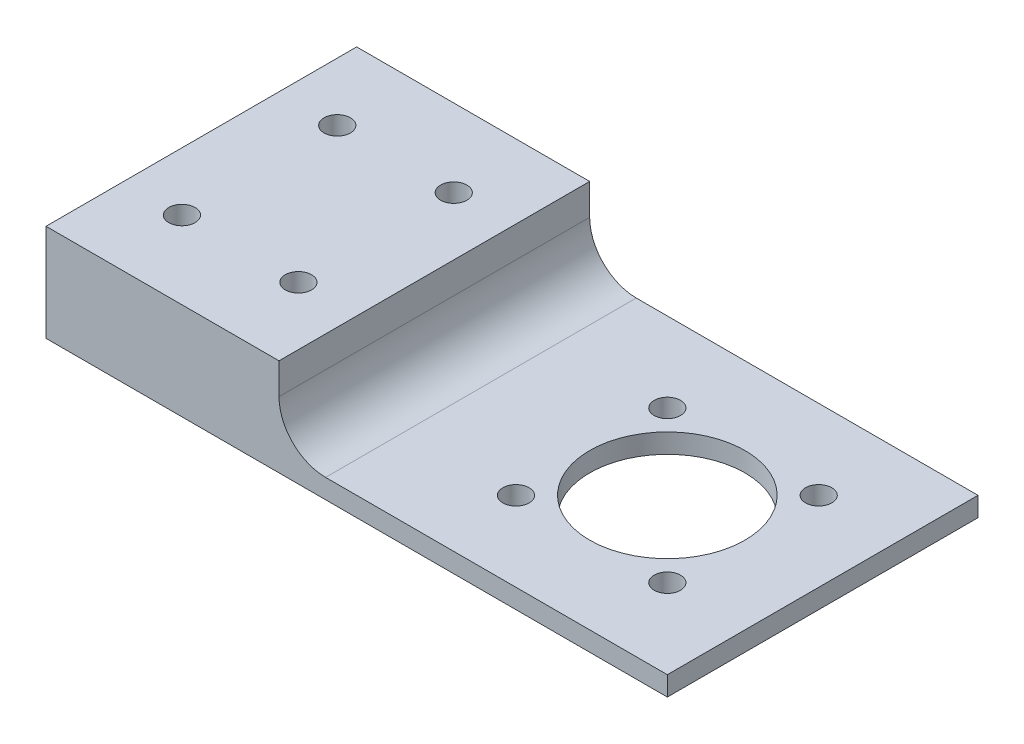
from build123d import *

# Parameters (mm, degrees)
BOSS_EXTRUDE1_DEPTH          = 3.175
SKETCH6_W                    = 38.1
SKETCH6_H                    = 50.8
BOSS_EXTRUDE3_DEPTH          = 12.7
FILLET1_R                    = 7.62
SKETCH2_R                    = 2.15265
MOUNTINGHOLESM4_DEPTH        = 3.175
SKETCH5_R                    = 12.7
HOLEFOR25MMOUTCROPPING_DEPTH = 3.175
SKETCH7_R                    = 2.15265
CUT_EXTRUDE4_DEPTH           = 15.875


with BuildPart() as part:
    # Sketch1 → Boss-Extrude1 (new body)
    with BuildSketch(Plane(origin=(0, 0, 0), x_dir=(1, 0, 0), z_dir=(0, 1, 0))):
        Polygon((50.8, 25.4), (63.5, 25.4), (63.5, -25.4), (50.8, -25.4), (0, -25.4), (-38.1, -25.4), (-38.1, 25.4), (0, 25.4), align=None)
    extrude(amount=BOSS_EXTRUDE1_DEPTH)

    # Sketch6 → Boss-Extrude3 (add)
    with BuildSketch(Plane(origin=(0, 3.175, 0), x_dir=(1, 0, 0), z_dir=(0, 1, 0))):
        with Locations((-19.05, 0)):
            Rectangle(SKETCH6_W, SKETCH6_H)
    extrude(amount=BOSS_EXTRUDE3_DEPTH)

    # Fillet1
    fillet1_edges = [part.edges().sort_by_distance(p)[0] for p in [
        (0, 3.175, 0),
    ]]
    fillet(fillet1_edges, radius=FILLET1_R)

    # Sketch2 → MountingHolesM4 (cut)
    with BuildSketch(Plane(origin=(0, 3.175, 0), x_dir=(1, 0, 0), z_dir=(0, 1, 0))):
        with Locations((50.474368671, 12.374368671)):
            Circle(SKETCH2_R)
        with Locations((50.474368671, -12.374368671)):
            Circle(SKETCH2_R)
        with Locations((25.725631329, -12.374368671)):
            Circle(SKETCH2_R)
        with Locations((25.725631329, 12.374368671)):
            Circle(SKETCH2_R)
    extrude(amount=-MOUNTINGHOLESM4_DEPTH, mode=Mode.SUBTRACT)

    # Sketch5 → HoleFor25mmOutCropping (cut)
    with BuildSketch(Plane(origin=(0, 3.175, 0), x_dir=(1, 0, 0), z_dir=(0, 1, 0))):
        with Locations((38.1, 0)):
            Circle(SKETCH5_R)
    extrude(amount=-HOLEFOR25MMOUTCROPPING_DEPTH, mode=Mode.SUBTRACT)

    # Sketch7 → Cut-Extrude4 (cut)
    with BuildSketch(Plane.XZ):
        with Locations((-9.525, -12.7)):
            Circle(SKETCH7_R)
        with Locations((-28.575, -12.7)):
            Circle(SKETCH7_R)
        with Locations((-9.525, 12.7)):
            Circle(SKETCH7_R)
        with Locations((-28.575, 12.7)):
            Circle(SKETCH7_R)
    extrude(amount=-CUT_EXTRUDE4_DEPTH, mode=Mode.SUBTRACT)


solid = part.part
